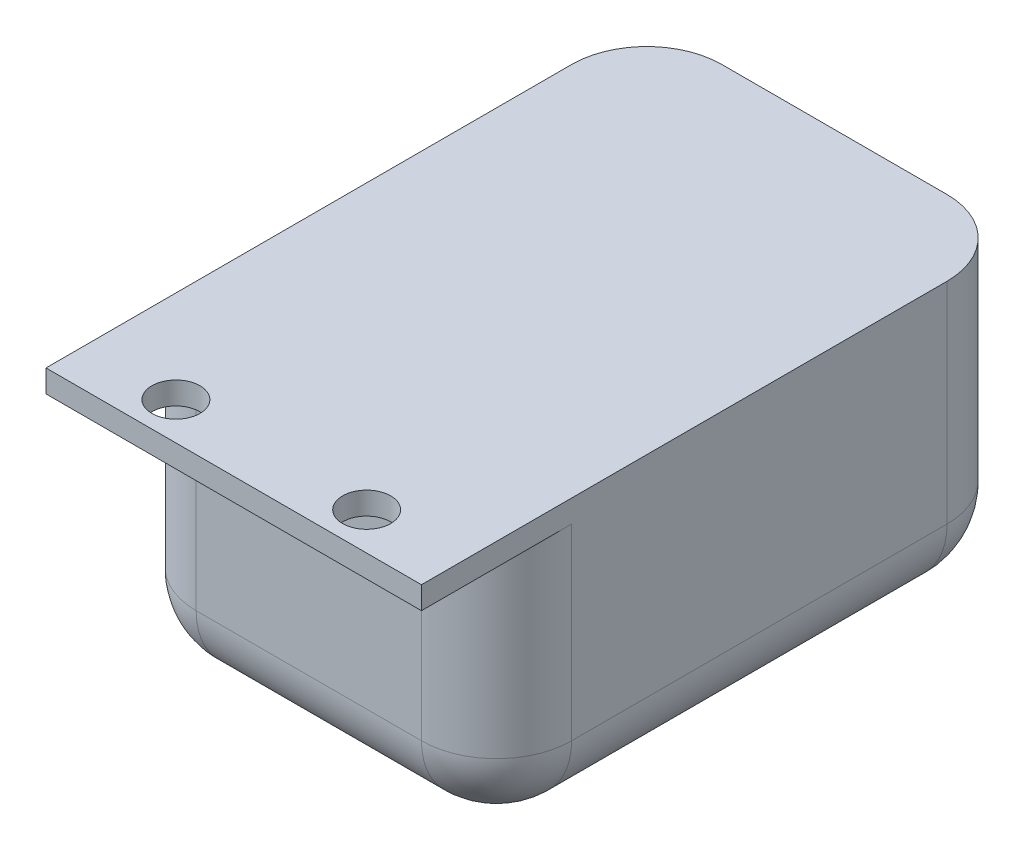
from build123d import *

# Parameters (mm, degrees)
SKETCH1_W           = 70
SKETCH1_H           = 35
BOSS_EXTRUDE1_DEPTH = 50
SHELL1_T            = -3
SKETCH2_W           = 50
SKETCH2_H           = 70
BOSS_EXTRUDE2_DEPTH = 3
SKETCH4_R           = 6.5
BOSS_EXTRUDE3_DEPTH = 6
CUT_EXTRUDE1_REACH  = 46
SKETCH5_R           = 4.5
SKETCH6_W           = 50
SKETCH6_H           = 3
BOSS_EXTRUDE4_DEPTH = 10
SKETCH8_R           = 3.2
CUT_EXTRUDE3_DEPTH  = 4
SKETCH9_R           = 3.2
CUT_EXTRUDE4_DEPTH  = 4
FILLET1_R           = 10
FILLET2_R           = 10


with BuildPart() as part:
    # Sketch1 → Boss-Extrude1 (new body)
    with BuildSketch(Plane(origin=(0, 0, 0), x_dir=(0, 0, -1), z_dir=(1, 0, 0))):
        Rectangle(SKETCH1_W, SKETCH1_H)
    extrude(amount=BOSS_EXTRUDE1_DEPTH)

    # Shell1
    shell1_openings = [part.faces().sort_by_distance(p)[0] for p in [
        (25, 17.5, 0),
    ]]
    offset(amount=SHELL1_T, openings=shell1_openings, kind=Kind.INTERSECTION)

    # Sketch2 → Boss-Extrude2 (add)
    with BuildSketch(Plane(origin=(0, 17.5, 0), x_dir=(1, 0, 0), z_dir=(0, 1, 0))):
        with Locations((25, 0)):
            Rectangle(SKETCH2_W, SKETCH2_H)
    extrude(amount=BOSS_EXTRUDE2_DEPTH)

    # Sketch4 → Boss-Extrude3 (add)
    with BuildSketch(Plane.XZ.offset(17.5)):
        with Locations((25, 0)):
            Circle(SKETCH4_R)
    extrude(amount=BOSS_EXTRUDE3_DEPTH)

    # Sketch5 → Cut-Extrude1 (cut, up to next)
    with BuildSketch(Plane.XZ.offset(23.5), mode=Mode.PRIVATE) as cut_extrude1_sk1:
        with Locations((25, 0)):
            Circle(SKETCH5_R)
    cut_extrude1_tool1 = extrude(cut_extrude1_sk1.sketch, amount=-CUT_EXTRUDE1_REACH, mode=Mode.PRIVATE) & part.part
    add(cut_extrude1_tool1.solids().sort_by_distance((25, -23.5, 0))[0], mode=Mode.SUBTRACT)

    # Sketch6 → Boss-Extrude4 (add)
    with BuildSketch(Plane.XY.offset(35)):
        with Locations((25, 19)):
            Rectangle(SKETCH6_W, SKETCH6_H)
    extrude(amount=BOSS_EXTRUDE4_DEPTH)

    # Sketch8 → Cut-Extrude3 (cut, through all)
    with BuildSketch(Plane.XZ.offset(-17.5)):
        with Locations((12.3, 40)):
            Circle(SKETCH8_R)
    extrude(amount=-CUT_EXTRUDE3_DEPTH, mode=Mode.SUBTRACT)

    # Sketch9 → Cut-Extrude4 (cut, through all)
    with BuildSketch(Plane.XZ.offset(-17.5)):
        with Locations((37.7, 40)):
            Circle(SKETCH9_R)
    extrude(amount=-CUT_EXTRUDE4_DEPTH, mode=Mode.SUBTRACT)

    # Fillet1
    fillet1_edges = [part.edges().sort_by_distance(p)[0] for p in [
        (50, -17.5, 0),
        (50, 1.5, -35),
        (0, -17.5, 0),
        (0, 0, 35),
        (50, 0, 35),
        (0, 1.5, -35),
        (25, -17.5, -35),
        (25, -17.5, 35),
    ]]
    fillet(fillet1_edges, radius=FILLET1_R)

    # Fillet2
    fillet2_edges = [part.edges().sort_by_distance(p)[0] for p in [
        (3, 1.5, -32),
        (25, -14.5, -32),
        (3, 1.5, 32),
        (3, -14.5, 0),
        (25, -14.5, 32),
        (47, 1.5, -32),
        (47, 1.5, 32),
        (47, -14.5, 0),
    ]]
    fillet(fillet2_edges, radius=FILLET2_R)


solid = part.part
